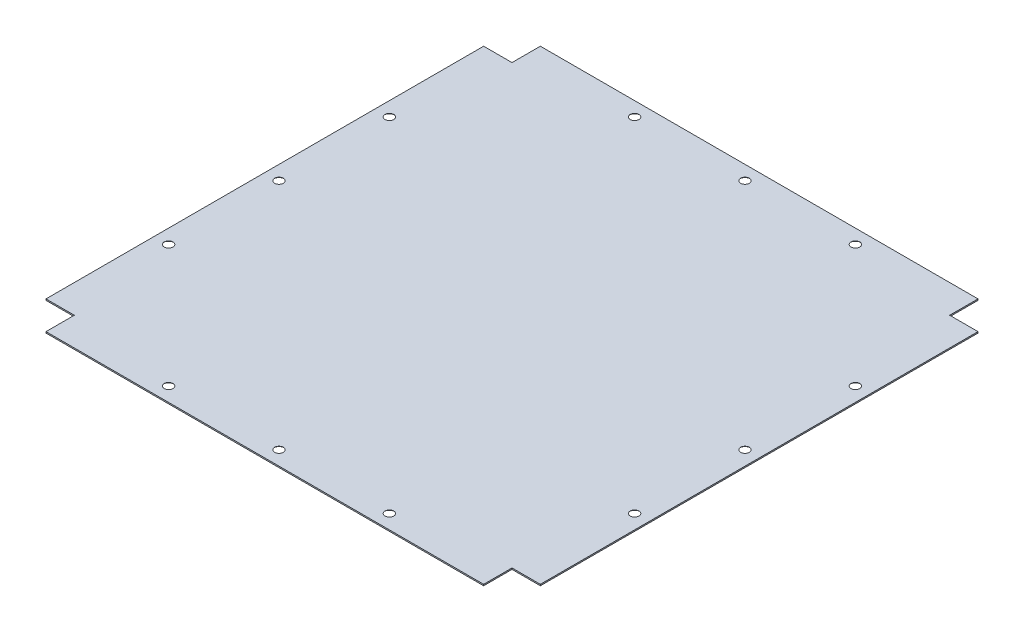
from build123d import *

# Parameters (mm, degrees)
BOSS_EXTRUDE2_DEPTH                            = 2
CSK_FOR_M8_FLAT_HEAD_MACHINE_SCREW2_AT_2_COUNT = 2
CSK_FOR_M8_FLAT_HEAD_MACHINE_SCREW2_AT_2_PITCH = 167.5
CSK_FOR_M8_FLAT_HEAD_MACHINE_SCREW2_AT_3_COUNT = 2
CSK_FOR_M8_FLAT_HEAD_MACHINE_SCREW2_AT_3_PITCH = 167.5
CSK_FOR_M8_FLAT_HEAD_MACHINE_SCREW2_AT_4_COUNT = 2
CSK_FOR_M8_FLAT_HEAD_MACHINE_SCREW2_AT_4_PITCH = 399.447430834
CSK_FOR_M8_FLAT_HEAD_MACHINE_SCREW2_AT_5_COUNT = 2
CSK_FOR_M8_FLAT_HEAD_MACHINE_SCREW2_AT_5_PITCH = 629.605630534


with BuildPart() as part:
    # Sketch3 → Boss-Extrude2 (new body)
    with BuildSketch(Plane(origin=(0, 0, 0), x_dir=(1, 0, 0), z_dir=(0, 1, 0))):
        Polygon((750, -707), (750, -43), (707, -43), (707, 0), (43, 0), (43, -43), (0, -43), (0, -707), (43, -707), (43, -750), (707, -750), (707, -707), align=None)
    extrude(amount=BOSS_EXTRUDE2_DEPTH)

    # Sketch9 → CSK for M8 Flat Head Machine Screw1 (revolve, cut)
    with BuildSketch(Plane(origin=(21.5, 0, 375), x_dir=(0, 0, -1), z_dir=(1, 0, 0))):
        Polygon((0, 0), (0, 2), (4.5, 2), (4.5, 4.15), (8.65, 0), align=None)
    csk_for_m8_flat_head_machine_screw1 = revolve(axis=Axis((21.5, -6.35, 375), (0, 1, 0)), mode=Mode.SUBTRACT)

    # Sketch12 → CSK for M8 Flat Head Machine Screw2 (revolve, cut)
    with BuildSketch(Plane(origin=(375, 0, 728.5), x_dir=(0, 0, -1), z_dir=(1, 0, 0))):
        Polygon((0, 0), (0, 2), (4.5, 2), (4.5, 4.15), (8.65, 0), align=None)
    csk_for_m8_flat_head_machine_screw2 = revolve(axis=Axis((375, -6.35, 728.5), (0, 1, 0)), mode=Mode.SUBTRACT)

    # CSK for M8 Flat Head Machine Screw2 at 2: CSK for M8 Flat Head Machine Screw2 ×2
    with Locations(*[(i * CSK_FOR_M8_FLAT_HEAD_MACHINE_SCREW2_AT_2_PITCH, 0, 0) for i in range(1, CSK_FOR_M8_FLAT_HEAD_MACHINE_SCREW2_AT_2_COUNT)]):
        add(csk_for_m8_flat_head_machine_screw2, mode=Mode.SUBTRACT)

    # CSK for M8 Flat Head Machine Screw2 at 3: CSK for M8 Flat Head Machine Screw2 ×2
    with Locations(*[(-i * CSK_FOR_M8_FLAT_HEAD_MACHINE_SCREW2_AT_3_PITCH, 0, 0) for i in range(1, CSK_FOR_M8_FLAT_HEAD_MACHINE_SCREW2_AT_3_COUNT)]):
        add(csk_for_m8_flat_head_machine_screw2, mode=Mode.SUBTRACT)

    # CSK for M8 Flat Head Machine Screw2 at 4: CSK for M8 Flat Head Machine Screw2 ×2
    with Locations(*[Vector(-0.884972521, 0, -0.46564325) * (i * CSK_FOR_M8_FLAT_HEAD_MACHINE_SCREW2_AT_4_PITCH) for i in range(1, CSK_FOR_M8_FLAT_HEAD_MACHINE_SCREW2_AT_4_COUNT)]):
        add(csk_for_m8_flat_head_machine_screw2, mode=Mode.SUBTRACT)

    # CSK for M8 Flat Head Machine Screw2 at 5: CSK for M8 Flat Head Machine Screw2 ×2
    with Locations(*[Vector(-0.561462577, 0, -0.827502129) * (i * CSK_FOR_M8_FLAT_HEAD_MACHINE_SCREW2_AT_5_PITCH) for i in range(1, CSK_FOR_M8_FLAT_HEAD_MACHINE_SCREW2_AT_5_COUNT)]):
        add(csk_for_m8_flat_head_machine_screw2, mode=Mode.SUBTRACT)

    # Mirror1: CSK for M8 Flat Head Machine Screw1, CSK for M8 Flat Head Machine Screw2 across plane
    add(csk_for_m8_flat_head_machine_screw1.mirror(Plane.ZY.offset(-375)), mode=Mode.SUBTRACT)
    add(csk_for_m8_flat_head_machine_screw2.mirror(Plane.ZY.offset(-375)), mode=Mode.SUBTRACT)

    # Mirror1 copy 1 sketch → Mirror1 copy 1 (revolve, cut)
    with BuildSketch(Plane(origin=(207.5, 0, 728.5), x_dir=(0, 0, -1), z_dir=(-1, 0, 0))):
        Polygon((0, 0), (0, -2), (4.5, -2), (4.5, -4.15), (8.65, 0), align=None)
    revolve(axis=Axis((207.5, -6.35, 728.5), (0, -1, 0)), mode=Mode.SUBTRACT)

    # Mirror1 copy 2 sketch → Mirror1 copy 2 (revolve, cut)
    with BuildSketch(Plane(origin=(542.5, 0, 728.5), x_dir=(0, 0, -1), z_dir=(-1, 0, 0))):
        Polygon((0, 0), (0, -2), (4.5, -2), (4.5, -4.15), (8.65, 0), align=None)
    revolve(axis=Axis((542.5, -6.35, 728.5), (0, -1, 0)), mode=Mode.SUBTRACT)

    # Mirror1 copy 3 sketch → Mirror1 copy 3 (revolve, cut)
    with BuildSketch(Plane(origin=(728.5, 0, 542.5), x_dir=(0, 0, -1), z_dir=(-1, 0, 0))):
        Polygon((0, 0), (0, -2), (4.5, -2), (4.5, -4.15), (8.65, 0), align=None)
    revolve(axis=Axis((728.5, -6.35, 542.5), (0, -1, 0)), mode=Mode.SUBTRACT)

    # Mirror1 copy 4 sketch → Mirror1 copy 4 (revolve, cut)
    with BuildSketch(Plane(origin=(728.5, 0, 207.5), x_dir=(0, 0, -1), z_dir=(-1, 0, 0))):
        Polygon((0, 0), (0, -2), (4.5, -2), (4.5, -4.15), (8.65, 0), align=None)
    revolve(axis=Axis((728.5, -6.35, 207.5), (0, -1, 0)), mode=Mode.SUBTRACT)

    # Mirror2: CSK for M8 Flat Head Machine Screw2 across plane
    add(csk_for_m8_flat_head_machine_screw2.mirror(Plane.XY.offset(375)), mode=Mode.SUBTRACT)

    # Mirror2 copy 1 sketch → Mirror2 copy 1 (revolve, cut)
    with BuildSketch(Plane(origin=(542.5, 0, 21.5), x_dir=(0, 0, 1), z_dir=(1, 0, 0))):
        Polygon((0, 0), (0, -2), (4.5, -2), (4.5, -4.15), (8.65, 0), align=None)
    revolve(axis=Axis((542.5, -6.35, 21.5), (0, -1, 0)), mode=Mode.SUBTRACT)

    # Mirror2 copy 2 sketch → Mirror2 copy 2 (revolve, cut)
    with BuildSketch(Plane(origin=(207.5, 0, 21.5), x_dir=(0, 0, 1), z_dir=(1, 0, 0))):
        Polygon((0, 0), (0, -2), (4.5, -2), (4.5, -4.15), (8.65, 0), align=None)
    revolve(axis=Axis((207.5, -6.35, 21.5), (0, -1, 0)), mode=Mode.SUBTRACT)

    # Mirror2 copy 3 sketch → Mirror2 copy 3 (revolve, cut)
    with BuildSketch(Plane(origin=(21.5, 0, 207.5), x_dir=(0, 0, 1), z_dir=(1, 0, 0))):
        Polygon((0, 0), (0, -2), (4.5, -2), (4.5, -4.15), (8.65, 0), align=None)
    revolve(axis=Axis((21.5, -6.35, 207.5), (0, -1, 0)), mode=Mode.SUBTRACT)

    # Mirror2 copy 4 sketch → Mirror2 copy 4 (revolve, cut)
    with BuildSketch(Plane(origin=(21.5, 0, 542.5), x_dir=(0, 0, 1), z_dir=(1, 0, 0))):
        Polygon((0, 0), (0, -2), (4.5, -2), (4.5, -4.15), (8.65, 0), align=None)
    revolve(axis=Axis((21.5, -6.35, 542.5), (0, -1, 0)), mode=Mode.SUBTRACT)


solid = part.part
